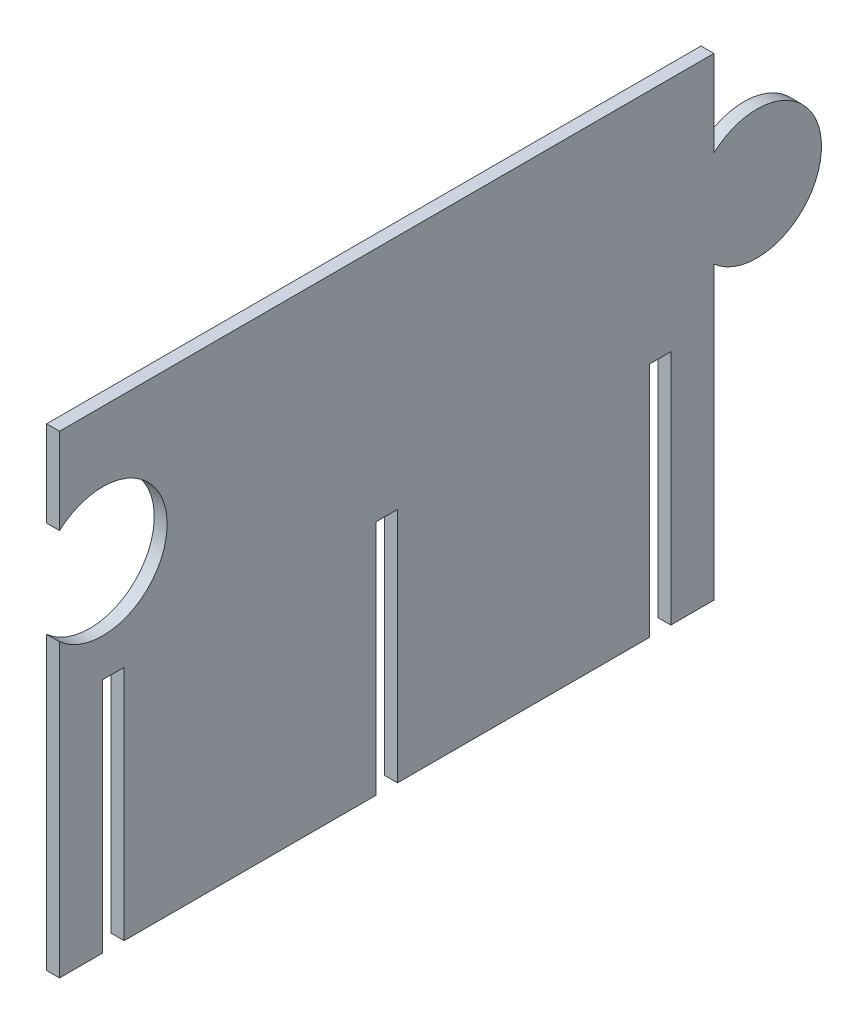
from build123d import *

# Parameters (mm, degrees)
BOSS_EXTRU_1_DEPTH = 3


with BuildPart() as part:
    # Esquisse2 → Boss.-Extru.1 (new body)
    with BuildSketch(Plane(origin=(0, 0, -25.32076404), x_dir=(0, 0, -1), z_dir=(1, 0, 0))):
        with BuildLine():
            Line((-45.329923666, 87.110380525), (-45.329923666, 67.110380525))
            ThreePointArc((-45.329923666, 67.110380525), (-20.329923666, 55.930040637), (-45.329923666, 44.74970075))
            Line((-45.329923666, 44.74970075), (-45.329923666, -22.889619475))
            Line((-45.329923666, -22.889619475), (-35.329923666, -22.889619475))
            Line((-35.329923666, -22.889619475), (-35.329923666, 32.110380525))
            Line((-35.329923666, 32.110380525), (-30.329923666, 32.110380525))
            Line((-30.329923666, 32.110380525), (-30.329923666, -22.889619475))
            Line((-30.329923666, -22.889619475), (28.170076334, -22.889619475))
            Line((28.170076334, -22.889619475), (28.170076334, 32.110380525))
            Line((28.170076334, 32.110380525), (33.170076334, 32.110380525))
            Line((33.170076334, 32.110380525), (33.170076334, -22.889619475))
            Line((33.170076334, -22.889619475), (91.670076334, -22.889619475))
            Line((91.670076334, -22.889619475), (91.670076334, 32.110380525))
            Line((91.670076334, 32.110380525), (96.670076334, 32.110380525))
            Line((96.670076334, 32.110380525), (96.670076334, -22.889619475))
            Line((96.670076334, -22.889619475), (106.670076334, -22.889619475))
            Line((106.670076334, -22.889619475), (106.670076334, 44.74970075))
            ThreePointArc((106.670076334, 44.74970075), (131.670076334, 55.930040637), (106.670076334, 67.110380525))
            Line((106.670076334, 67.110380525), (106.670076334, 87.110380525))
            Line((106.670076334, 87.110380525), (-45.329923666, 87.110380525))
        make_face()
    extrude(amount=BOSS_EXTRU_1_DEPTH)


solid = part.part
